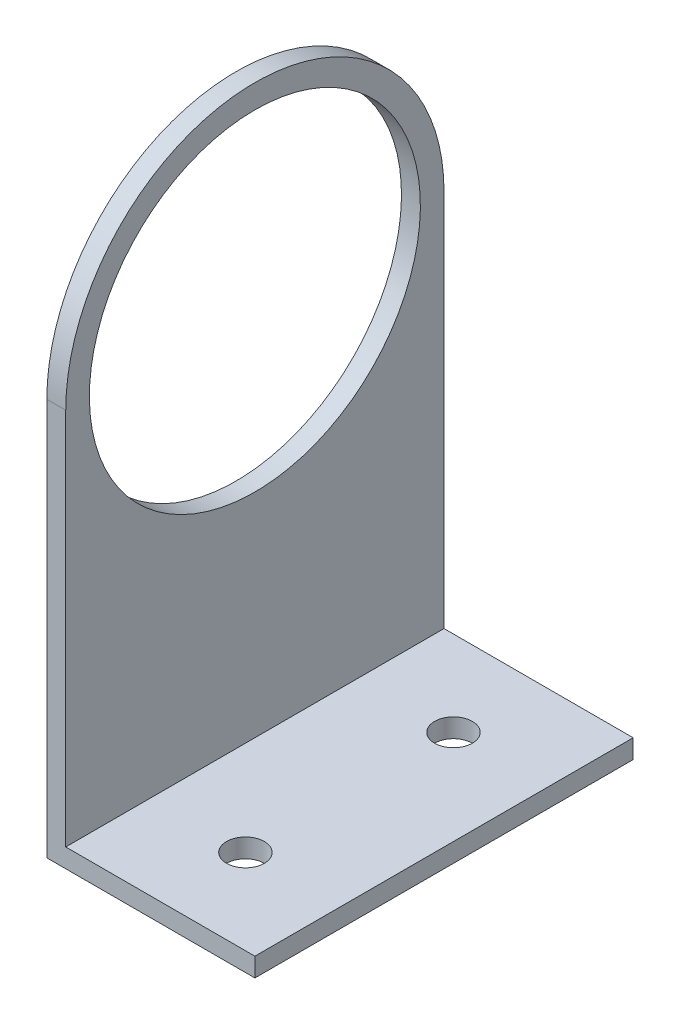
from build123d import *

# Parameters (mm, degrees)
BOSS_EXTRUDE1_DEPTH = 40
CUT_EXTRUDE1_REACH  = 4
SKETCH2_R           = 17.5
CUT_EXTRUDE2_REACH  = 4
CUT_EXTRUDE3_REACH  = 4
SKETCH6_R           = 2


with BuildPart() as part:
    # Sketch1 → Boss-Extrude1 (new body)
    with BuildSketch(Plane.XY):
        Polygon((0, 0), (0, 62), (2, 62), (2, 2), (22, 2), (22, 0), align=None)
    extrude(amount=BOSS_EXTRUDE1_DEPTH)

    # Sketch2 → Cut-Extrude1 (cut, up to next)
    with BuildSketch(Plane(origin=(2, 0, 0), x_dir=(0, 0, -1), z_dir=(1, 0, 0)), mode=Mode.PRIVATE) as cut_extrude1_sk1:
        with Locations((-20, 42)):
            Circle(SKETCH2_R)
    cut_extrude1_tool1 = extrude(cut_extrude1_sk1.sketch, amount=-CUT_EXTRUDE1_REACH, mode=Mode.PRIVATE) & part.part
    add(cut_extrude1_tool1.solids().sort_by_distance((2, 42, 20))[0], mode=Mode.SUBTRACT)

    # Sketch5 → Cut-Extrude2 (cut, up to next)
    with BuildSketch(Plane(origin=(2, 0, 0), x_dir=(0, 0, -1), z_dir=(1, 0, 0)), mode=Mode.PRIVATE) as cut_extrude2_sk1:
        with BuildLine():
            Line((-40, 62), (-40, 42))
            ThreePointArc((-40, 42), (-34.142135624, 56.142135624), (-20, 62))
            Line((-20, 62), (-40, 62))
        make_face()
    cut_extrude2_tool1 = extrude(cut_extrude2_sk1.sketch, amount=-CUT_EXTRUDE2_REACH, mode=Mode.PRIVATE) & part.part
    add(cut_extrude2_tool1.solids().sort_by_distance((2, 57.532641, 35.532641))[0], mode=Mode.SUBTRACT)
    # Sketch5 → Cut-Extrude2 (cut, up to next)
    with BuildSketch(Plane(origin=(2, 0, 0), x_dir=(0, 0, -1), z_dir=(1, 0, 0)), mode=Mode.PRIVATE) as cut_extrude2_sk2:
        with BuildLine():
            Line((0, 62), (-20, 62))
            ThreePointArc((-20, 62), (-5.857864376, 56.142135624), (0, 42))
            Line((0, 42), (0, 62))
        make_face()
    cut_extrude2_tool2 = extrude(cut_extrude2_sk2.sketch, amount=-CUT_EXTRUDE2_REACH, mode=Mode.PRIVATE) & part.part
    add(cut_extrude2_tool2.solids().sort_by_distance((2, 57.532641, 4.467359))[0], mode=Mode.SUBTRACT)

    # Sketch6 → Cut-Extrude3 (cut, up to next)
    with BuildSketch(Plane(origin=(0, 2, 0), x_dir=(1, 0, 0), z_dir=(0, 1, 0)), mode=Mode.PRIVATE) as cut_extrude3_sk1:
        with Locations((12, -9)):
            Circle(SKETCH6_R)
    cut_extrude3_tool1 = extrude(cut_extrude3_sk1.sketch, amount=-CUT_EXTRUDE3_REACH, mode=Mode.PRIVATE) & part.part
    add(cut_extrude3_tool1.solids().sort_by_distance((12, 2, 9))[0], mode=Mode.SUBTRACT)
    # Sketch6 → Cut-Extrude3 (cut, up to next)
    with BuildSketch(Plane(origin=(0, 2, 0), x_dir=(1, 0, 0), z_dir=(0, 1, 0)), mode=Mode.PRIVATE) as cut_extrude3_sk2:
        with Locations((12, -31)):
            Circle(SKETCH6_R)
    cut_extrude3_tool2 = extrude(cut_extrude3_sk2.sketch, amount=-CUT_EXTRUDE3_REACH, mode=Mode.PRIVATE) & part.part
    add(cut_extrude3_tool2.solids().sort_by_distance((12, 2, 31))[0], mode=Mode.SUBTRACT)


solid = part.part
